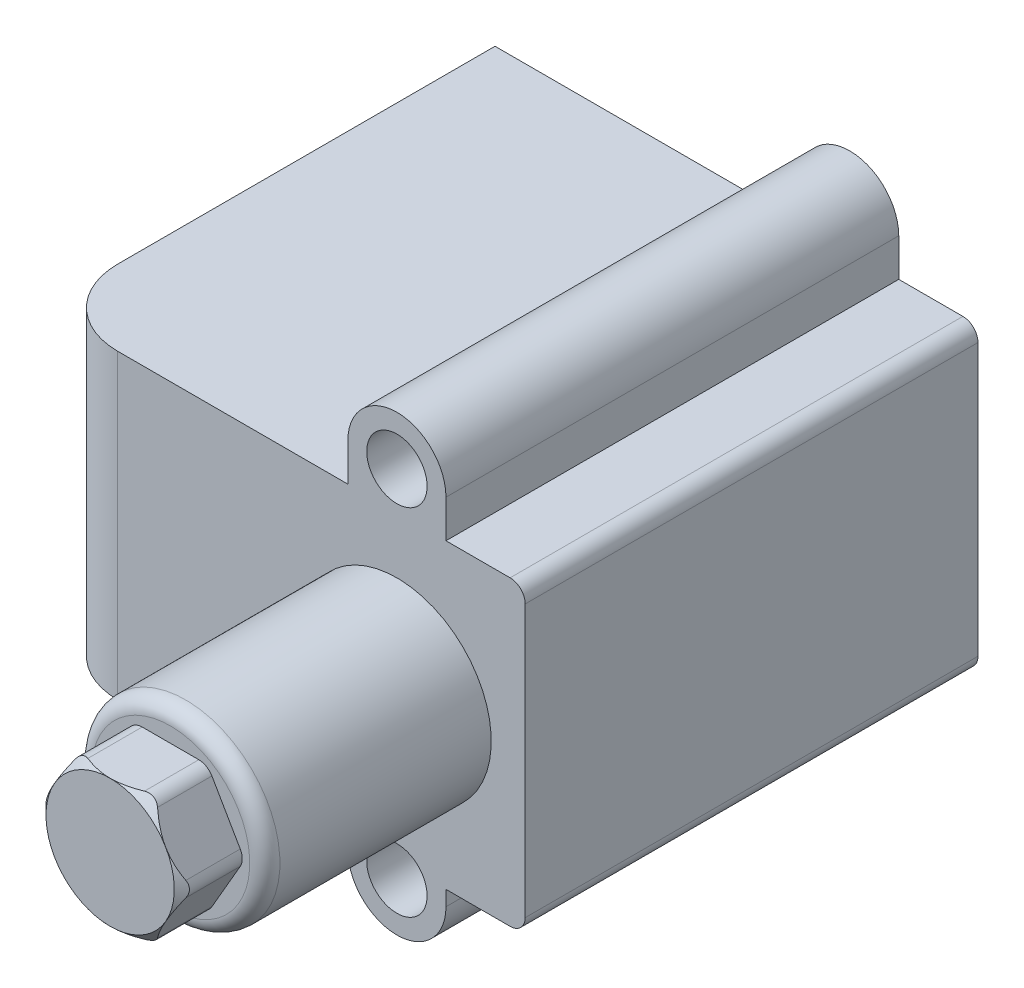
from build123d import *

# Parameters (mm, degrees)
SKETCH_1_R               = 4
SKETCH_1_R_2             = 5.5
EXTRUDE_1_DEPTH          = 60
FILLET_1_R               = 10
SKETCH_2_R               = 12.5
EXTRUDE_2_DEPTH          = 30
HOLE_WIZARD_G3_8_1_D     = 15.25
HOLE_WIZARD_G3_8_1_DEPTH = 10
HOLE_WIZARD_G3_8_1_TIP   = 4.58156222
EXTRUDE_3_DEPTH          = 8
FILLET_2_R               = 2
FILLET_3_R               = 2


with BuildPart() as part:
    # 草图1 → 凸台-拉伸1 (new body)
    with BuildSketch(Plane.XY):
        with BuildLine():
            Line((-6.5, 25), (-6.5, 20))
            Line((-6.5, 20), (-47, 20))
            Line((-47, 20), (-47, -20))
            Line((-47, -20), (-6.5, -20))
            Line((-6.5, -20), (-6.5, -22))
            ThreePointArc((-6.5, -22), (0, -28.5), (6.5, -22))
            Line((6.5, -22), (6.5, -20))
            Line((6.5, -20), (17, -20))
            Line((17, -20), (17, 20))
            Line((17, 20), (6.5, 20))
            Line((6.5, 20), (6.5, 25))
            ThreePointArc((6.5, 25), (0, 31.5), (-6.5, 25))
        make_face()
        with Locations((0, 25)):
            Circle(SKETCH_1_R, mode=Mode.SUBTRACT)
        with Locations((0, -22)):
            Circle(SKETCH_1_R, mode=Mode.SUBTRACT)
        Circle(SKETCH_1_R_2, mode=Mode.SUBTRACT)
    extrude(amount=EXTRUDE_1_DEPTH)

    # 圆角1
    fillet_1_edges = [part.edges().sort_by_distance(p)[0] for p in [
        (-47, 0, 60),
    ]]
    fillet(fillet_1_edges, radius=FILLET_1_R)

    # 草图2 → 凸台-拉伸2 (add)
    with BuildSketch(Plane.XY.offset(60)):
        Circle(SKETCH_2_R)
    extrude(amount=EXTRUDE_2_DEPTH)

    # G3/8 螺纹孔1
    with Locations(Plane(origin=(0, -20, 0), x_dir=(-1, 0, 0), z_dir=(0, -1, 0))):
        with Locations((33, -46)):
            Hole(HOLE_WIZARD_G3_8_1_D / 2, depth=HOLE_WIZARD_G3_8_1_DEPTH)
            with Locations((0, 0, -(HOLE_WIZARD_G3_8_1_DEPTH + HOLE_WIZARD_G3_8_1_TIP / 2))):  # 118° drill point
                Cone(0, HOLE_WIZARD_G3_8_1_D / 2, HOLE_WIZARD_G3_8_1_TIP, mode=Mode.SUBTRACT)

    # 草图6 → 凸台-拉伸3 (add)
    with BuildSketch(Plane.XY.offset(90)):
        Polygon((9.814954576, 0), (4.907477288, 8.5), (-4.907477288, 8.5), (-9.814954576, 0), (-4.907477288, -8.5), (4.907477288, -8.5), align=None)
    extrude(amount=EXTRUDE_3_DEPTH)

    # 圆角2
    fillet_2_edges = [part.edges().sort_by_distance(p)[0] for p in [
        (17, 20, 30),
        (17, -20, 30),
        (-12.5, 0, 90),
    ]]
    fillet(fillet_2_edges, radius=FILLET_2_R)

    # 圆角3
    fillet_3_edges = [part.edges().sort_by_distance(p)[0] for p in [
        (4.907477288, -8.5, 94),
        (9.814954576, 0, 94),
        (4.907477288, 8.5, 94),
        (-4.907477288, 8.5, 94),
        (-9.814954576, 0, 94),
        (-4.907477288, -8.5, 94),
    ]]
    fillet(fillet_3_edges, radius=FILLET_3_R)

    # 草图7 → 切除-旋转1 (revolve, cut)
    with BuildSketch(Plane(origin=(0, 0, 0), x_dir=(1, 0, 0), z_dir=(0, 1, 0))):
        Polygon((-9.505553499, -96.994446501), (-8.5, -98), (-9.505553499, -98), align=None)
    revolve(axis=Axis((0, 0, -9.70684158), (0, 0, 1)), mode=Mode.SUBTRACT)


solid = part.part
